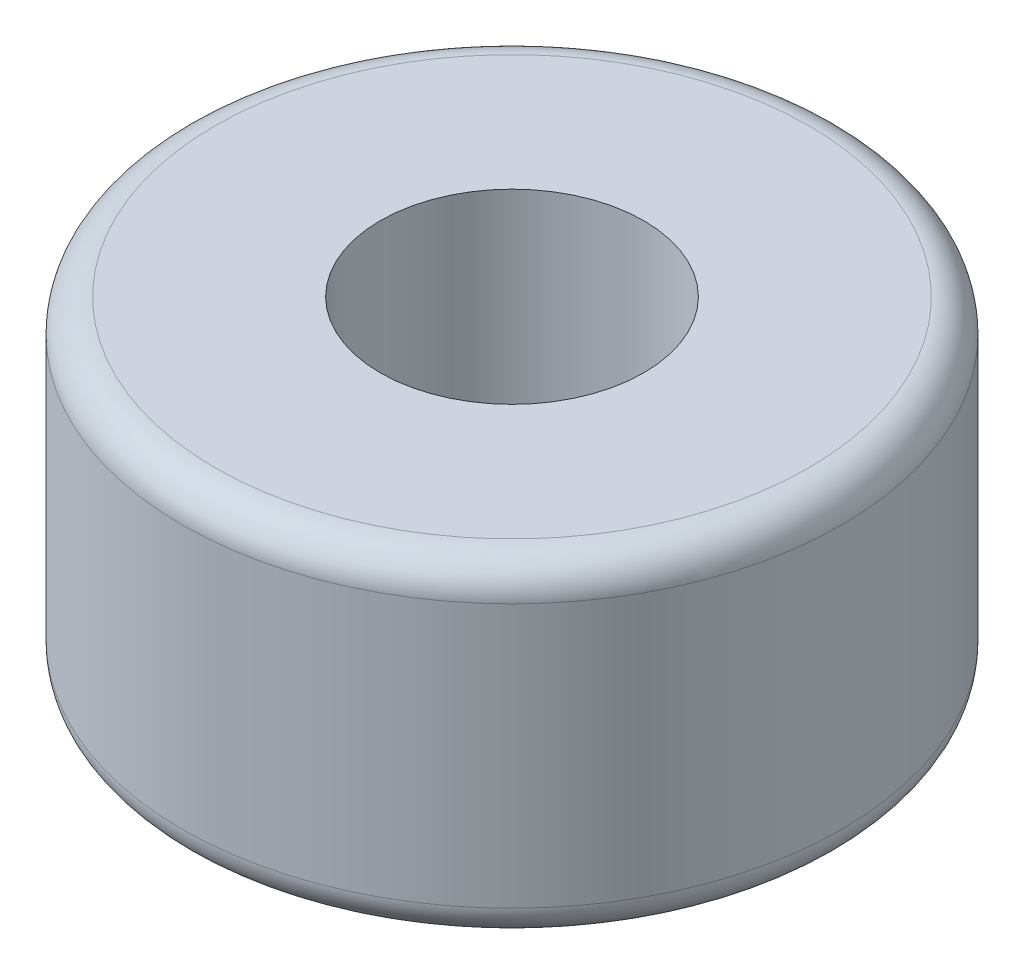
from build123d import *

# Parameters (mm, degrees)
SKETCH1_R           = 10
SKETCH1_R_2         = 4
BOSS_EXTRUDE1_DEPTH = 10
FILLET1_R           = 1


with BuildPart() as part:
    # Sketch1 → Boss-Extrude1 (new body)
    with BuildSketch(Plane(origin=(0, 0, 0), x_dir=(1, 0, 0), z_dir=(0, 1, 0))):
        Circle(SKETCH1_R)
        Circle(SKETCH1_R_2, mode=Mode.SUBTRACT)
    extrude(amount=BOSS_EXTRUDE1_DEPTH)

    # Fillet1
    fillet1_edges = [part.edges().sort_by_distance(p)[0] for p in [
        (-10, 0, 0),
        (-10, 10, 0),
    ]]
    fillet(fillet1_edges, radius=FILLET1_R)


solid = part.part
